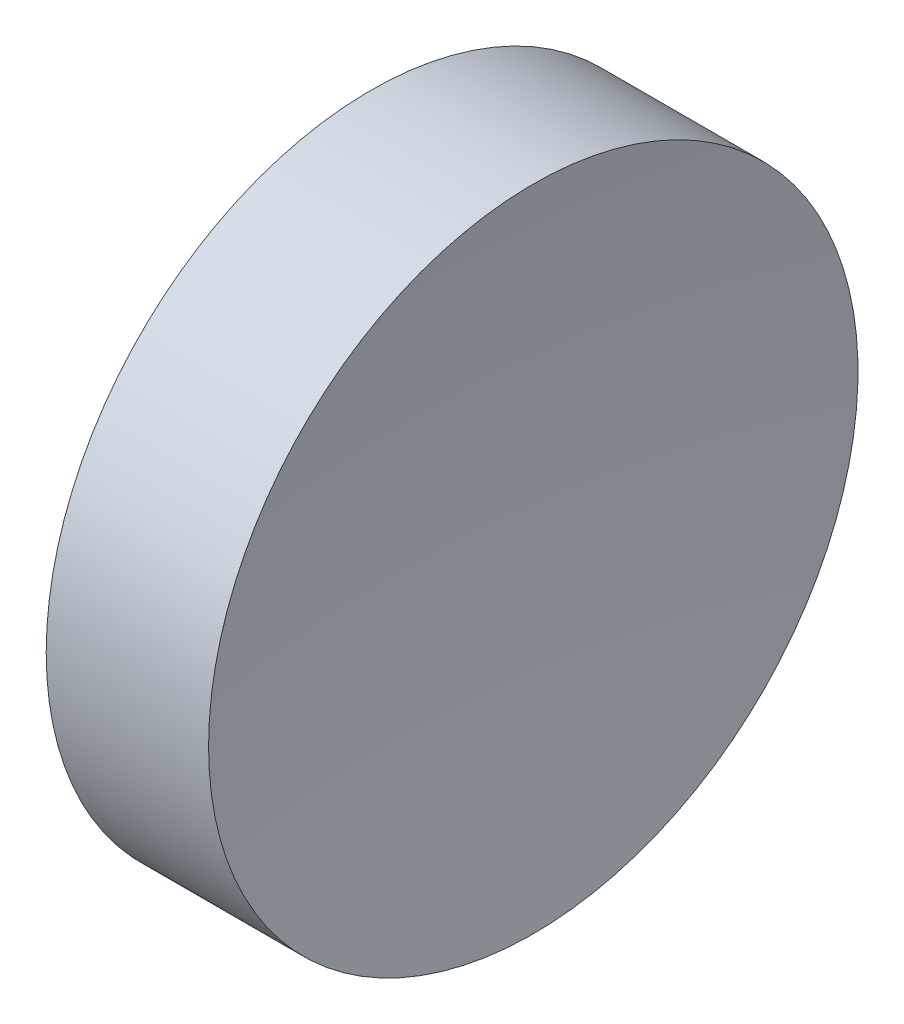
from build123d import *


with BuildPart() as part:
    # 草图1 → 旋转1 (revolve)
    with BuildSketch(Plane(origin=(0, 0, 0), x_dir=(1, 0, 0), z_dir=(0, 1, 0)), mode=Mode.PRIVATE) as revolve_1_sk:
        with BuildLine():
            Line((0, 0), (5.54, 0))
            ThreePointArc((5.54, 0), (5.742637384, 6.362893601), (6.3497283, 12.7))
            Line((6.3497283, 12.7), (0, 12.7))
            Line((0, 12.7), (0, 0))
        make_face()
    revolve(revolve_1_sk.sketch.rotate(Axis((0, 0, 0), (1, 0, 0)), 180), axis=Axis((0, 0, 0), (1, 0, 0)))  # turned: the seam where the file's is


solid = part.part
